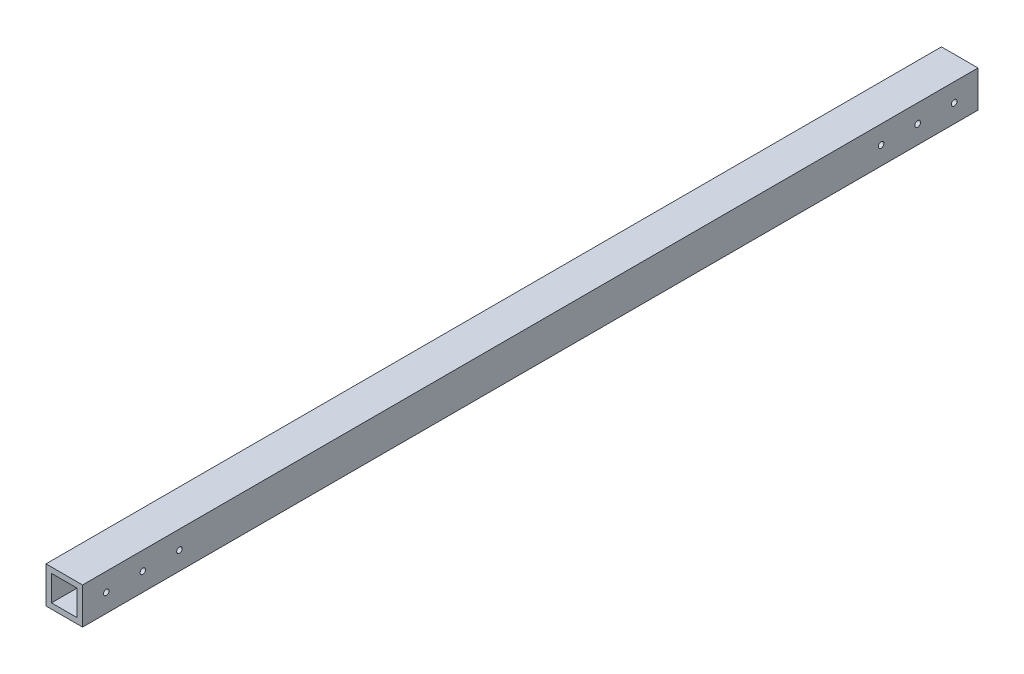
from build123d import *

# Parameters (mm, degrees)
SKETCH_1_W          = 20
SKETCH_1_H          = 20
EXTRUDE_1_DEPTH     = 490
SKETCH_2_W          = 14
SKETCH_2_H          = 14
CUT_EXTRUDE_1_DEPTH = 491
SKETCH_3_R          = 1.5
CUT_EXTRUDE_2_DEPTH = 80
SKETCH_4_R          = 1.55
CUT_EXTRUDE_3_DEPTH = 27


with BuildPart() as part:
    # 草图1 → 凸台-拉伸1 (new body)
    with BuildSketch(Plane.XY):
        with Locations((0.666666667, 1.006147649)):
            Rectangle(SKETCH_1_W, SKETCH_1_H)
    extrude(amount=EXTRUDE_1_DEPTH)

    # 草图2 → 切除-拉伸1 (cut, through all)
    with BuildSketch(Plane(origin=(0, 0, 0), x_dir=(-1, 0, 0), z_dir=(0, 0, -1))):
        with Locations((-0.666666667, 1.006147649)):
            Rectangle(SKETCH_2_W, SKETCH_2_H)
    extrude(amount=-CUT_EXTRUDE_1_DEPTH, mode=Mode.SUBTRACT)

    # 草图3 → 切除-拉伸2 (cut)
    with BuildSketch(Plane(origin=(10.666666667, 0, 0), x_dir=(0, 0, -1), z_dir=(1, 0, 0))):
        with Locations((-477, 1.006147649)):
            Circle(SKETCH_3_R)
        with Locations((-457, 1.006147649)):
            Circle(SKETCH_3_R)
        with Locations((-437, 1.006147649)):
            Circle(SKETCH_3_R)
    extrude(amount=-CUT_EXTRUDE_2_DEPTH, mode=Mode.SUBTRACT)

    # 草图4 → 切除-拉伸3 (cut)
    with BuildSketch(Plane.ZY.offset(9.333333333)):
        with Locations((13, 1.006147649)):
            Circle(SKETCH_4_R)
        with Locations((33, 1.006147649)):
            Circle(SKETCH_4_R)
        with Locations((53, 1.006147649)):
            Circle(SKETCH_4_R)
    extrude(amount=-CUT_EXTRUDE_3_DEPTH, mode=Mode.SUBTRACT)


solid = part.part
